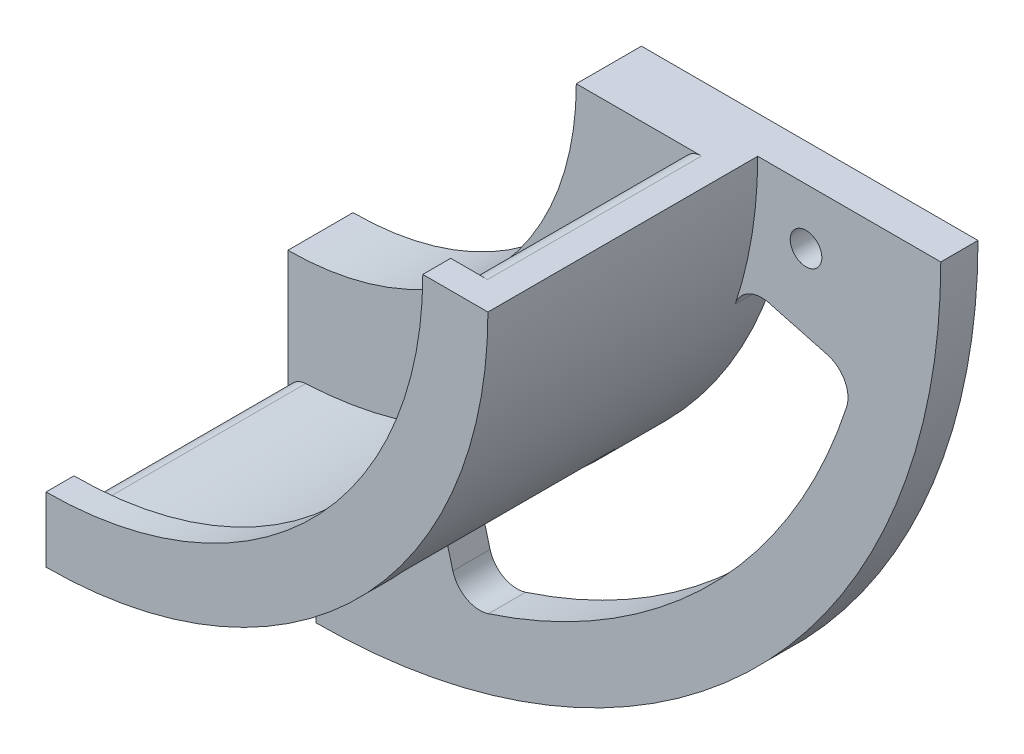
from build123d import *

# Parameters (mm, degrees)
EXTRUDE_1_DEPTH = 3
EXTRUDE_2_DEPTH = 23
EXTRUDE_3_DEPTH = 3
FILLET_1_R      = 2
EXTRUDE_START   = 4
SKETCH_4_R      = 1.7
EXTRUDE_4_DEPTH = 4
FILLET_2_R      = 3


with BuildPart() as part:
    # 草图1 → 凸台-拉伸1 (new body)
    with BuildSketch(Plane.XY):
        with BuildLine():
            Line((-16.680000946, -37.497442229), (-16.680000946, -53.997442229))
            ThreePointArc((-16.680000946, -53.997442229), (16.90757116, -40.085014335), (30.819999054, -6.497442229))
            Line((30.819999054, -6.497442229), (14.319999054, -6.497442229))
            ThreePointArc((14.319999054, -6.497442229), (5.240309271, -28.417752446), (-16.680000946, -37.497442229))
        make_face()
    extrude(amount=EXTRUDE_1_DEPTH)

    # 草图2 → 凸台-拉伸2 (add)
    with BuildSketch(Plane.XY.offset(3)):
        with BuildLine():
            Line((-16.680000946, -48.997442229), (-16.680000946, -53.997442229))
            ThreePointArc((-16.680000946, -53.997442229), (0.33591272, -50.84503159), (15.093251764, -41.806228844))
            Line((15.093251764, -41.806228844), (11.552232101, -38.265209182))
            ThreePointArc((11.552232101, -38.265209182), (-1.578346989, -46.223882389), (-16.680000946, -48.997442229))
        make_face()
        with BuildLine():
            Line((25.819999054, -6.497442229), (30.819999054, -6.497442229))
            ThreePointArc((30.819999054, -6.497442229), (27.667588415, -23.513355895), (18.628785669, -38.270694938))
            Line((18.628785669, -38.270694938), (15.087766007, -34.729675276))
            ThreePointArc((15.087766007, -34.729675276), (23.046439214, -21.599096186), (25.819999054, -6.497442229))
        make_face()
    extrude(amount=EXTRUDE_2_DEPTH)

    # 草图3 → 凸台-拉伸3 (add)
    with BuildSketch(Plane.XY.offset(26)):
        with BuildLine():
            Line((-16.680000946, -46.997442229), (-16.680000946, -53.997442229))
            ThreePointArc((-16.680000946, -53.997442229), (16.90757116, -40.085014335), (30.819999054, -6.497442229))
            Line((30.819999054, -6.497442229), (23.819999054, -6.497442229))
            ThreePointArc((23.819999054, -6.497442229), (11.957823692, -35.135266867), (-16.680000946, -46.997442229))
        make_face()
    extrude(amount=EXTRUDE_3_DEPTH)

    # 圆角1
    fillet_1_edges = [part.edges().sort_by_distance(p)[0] for p in [
        (25.819999054, -6.497442229, 14.5),
        (15.087766007, -34.729675276, 14.5),
        (11.552232101, -38.265209182, 14.5),
        (-16.680000946, -48.997442229, 14.5),
    ]]
    fillet(fillet_1_edges, radius=FILLET_1_R)

    # 草图4 → 凸台-拉伸4 (add)
    with BuildSketch(Plane(origin=(0, 0, 0), x_dir=(-1, 0, 0), z_dir=(0, 0, -1)).offset(EXTRUDE_START)):
        with BuildLine():
            Line((16.680000946, -73.672586442), (16.680000946, -37.497442229))
            ThreePointArc((16.680000946, -37.497442229), (-5.240309271, -28.417752446), (-14.319999054, -6.497442229))
            Line((-14.319999054, -6.497442229), (-50.495143267, -6.497442229))
            ThreePointArc((-50.495143267, -6.497442229), (-30.819999054, -53.997442229), (16.680000946, -73.672586442))
        make_face()
        with Locations((10.680000946, -59.187305067)):
            Circle(SKETCH_4_R, mode=Mode.SUBTRACT)
        with Locations((-36.009861892, -12.497442229)):
            Circle(SKETCH_4_R, mode=Mode.SUBTRACT)
        with BuildLine():
            Line((-41.275548631, -22.026584935), (-29.201475803, -18.791346871))
            ThreePointArc((-29.201475803, -18.791346871), (-16.90757116, -40.085014335), (4.386096304, -52.378918978))
            Line((4.386096304, -52.378918978), (1.15085824, -64.452991806))
            ThreePointArc((1.15085824, -64.452991806), (-25.746405925, -48.9238491), (-41.275548631, -22.026584935))
        make_face(mode=Mode.SUBTRACT)
    extrude(amount=-EXTRUDE_4_DEPTH)

    # 圆角2
    fillet_2_edges = [part.edges().sort_by_distance(p)[0] for p in [
        (29.201475803, -18.791346871, -2),
        (41.275548631, -22.026584935, -2),
        (-1.15085824, -64.452991806, -2),
        (-4.386096304, -52.378918978, -2),
    ]]
    fillet(fillet_2_edges, radius=FILLET_2_R)


solid = part.part
